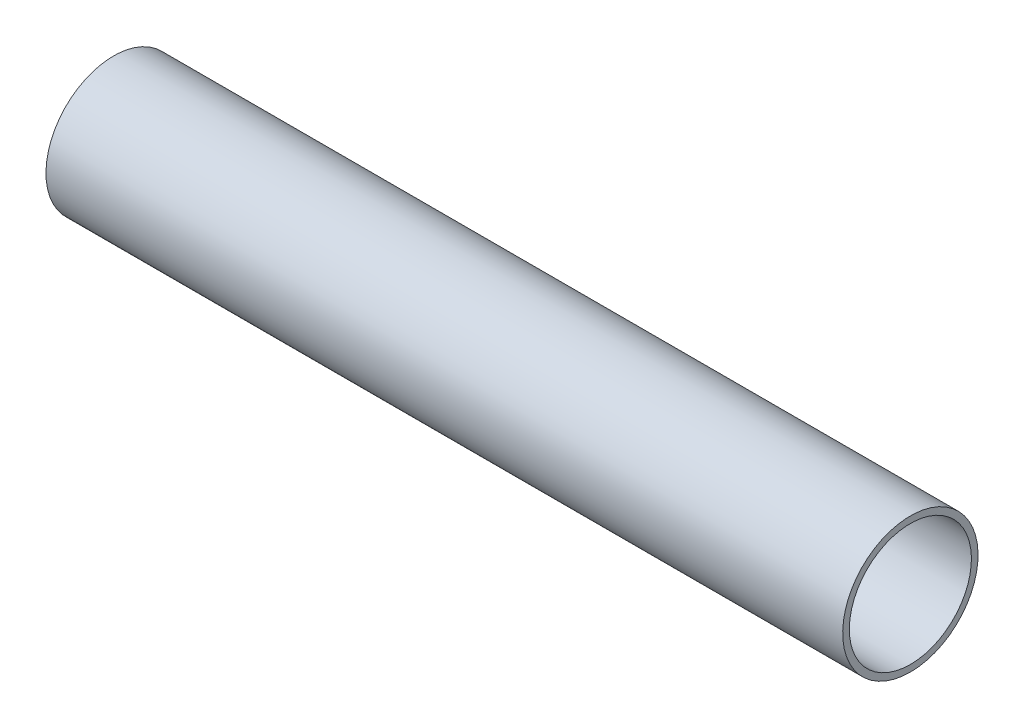
from build123d import *

# Parameters (mm, degrees)
SKETCH1_W = 78.3
SKETCH1_H = 0.65


with BuildPart() as part:
    # Sketch1 → Revolve1 (revolve)
    with BuildSketch(Plane.XY):
        with Locations((-631.748230203, -6.325440289)):
            Rectangle(SKETCH1_W, SKETCH1_H)
    revolve(axis=Axis((-666.248230203, -0.000440289, 0), (1, 0, 0)))


solid = part.part
